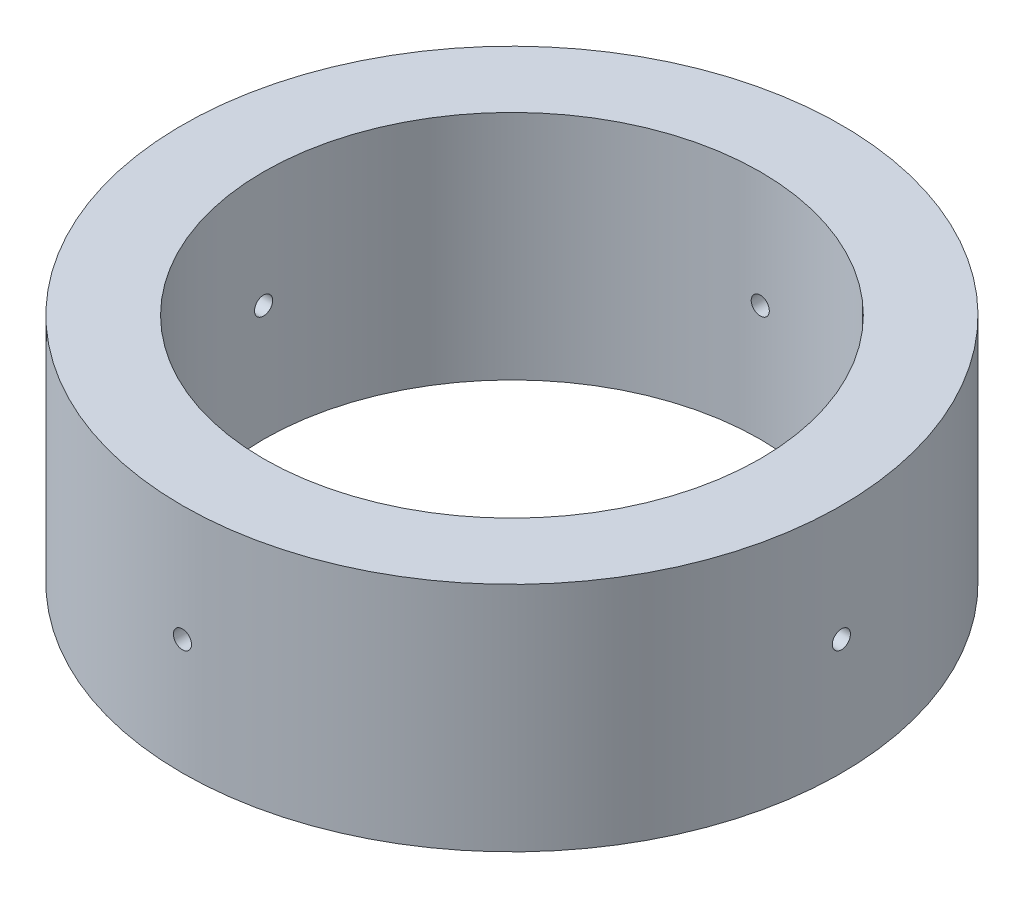
from build123d import *

# Parameters (mm, degrees)
SKETCH1_R           = 36.1315
SKETCH1_R_2         = 27.2415
BOSS_EXTRUDE1_DEPTH = 25.4
CUT_EXTRUDE1_START  = -8.908075
SKETCH2_R           = 0.9921875
CUT_EXTRUDE1_DEPTH  = 8.908075
CIRPATTERN1_COUNT   = 4


with BuildPart() as part:
    # Sketch1 → Boss-Extrude1 (new body)
    with BuildSketch(Plane(origin=(0, 0, 0), x_dir=(1, 0, 0), z_dir=(0, 1, 0))):
        Circle(SKETCH1_R)
        Circle(SKETCH1_R_2, mode=Mode.SUBTRACT)
    extrude(amount=BOSS_EXTRUDE1_DEPTH)

    # Sketch2 → Cut-Extrude1 (cut)
    with BuildSketch(Plane.XY.offset(36.1315).offset(CUT_EXTRUDE1_START)):
        with Locations((0, 12.7)):
            Circle(SKETCH2_R)
    cut_extrude1 = extrude(amount=CUT_EXTRUDE1_DEPTH, mode=Mode.SUBTRACT)

    # CirPattern1: Cut-Extrude1 ×4 about axis
    cirpattern1_axis = Axis((0, 25.4, 0), (0, -1, 0))
    for i in range(1, CIRPATTERN1_COUNT):
        add(cut_extrude1.rotate(cirpattern1_axis, i * 360 / CIRPATTERN1_COUNT), mode=Mode.SUBTRACT)


solid = part.part
